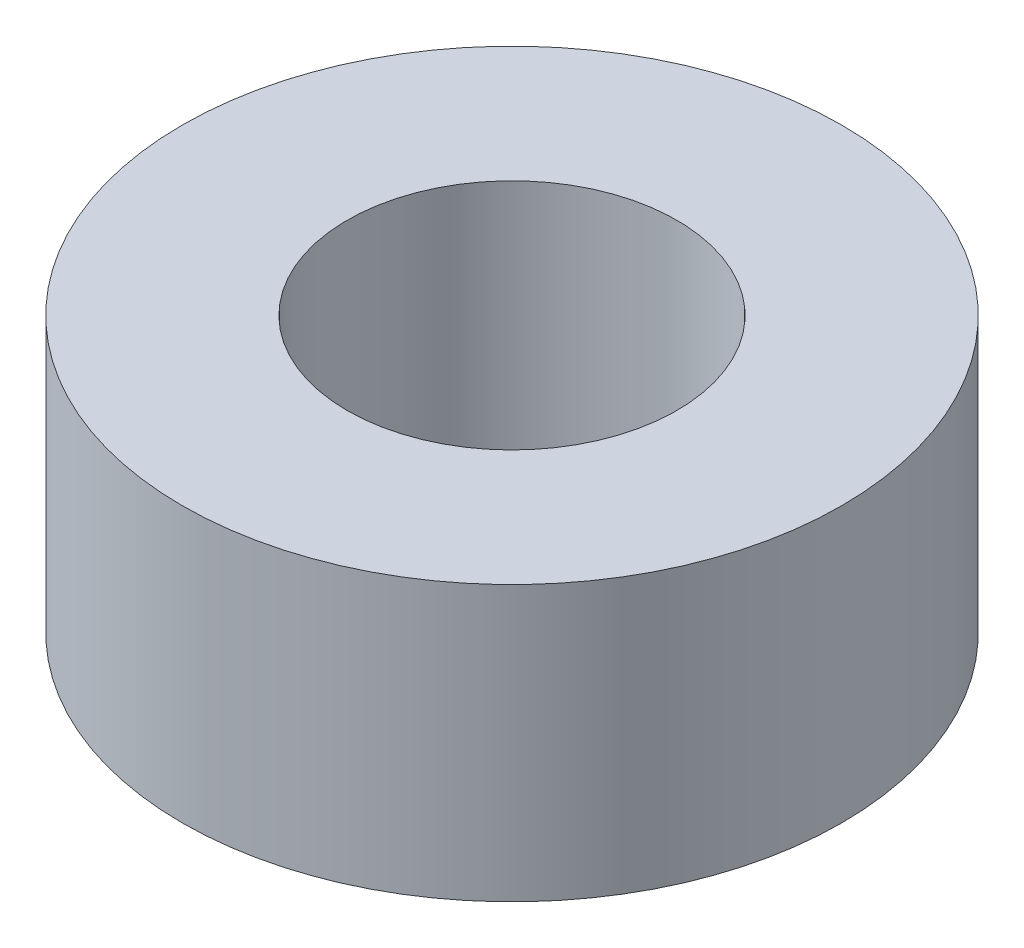
from build123d import *

# Parameters (mm, degrees)
SKETCH1_R           = 3
SKETCH1_R_2         = 1.5
BOSS_EXTRUDE1_DEPTH = 2.5


with BuildPart() as part:
    # Sketch1 → Boss-Extrude1 (new body)
    with BuildSketch(Plane(origin=(0, 0, 0), x_dir=(1, 0, 0), z_dir=(0, 1, 0))):
        Circle(SKETCH1_R)
        Circle(SKETCH1_R_2, mode=Mode.SUBTRACT)
    extrude(amount=BOSS_EXTRUDE1_DEPTH)


solid = part.part
